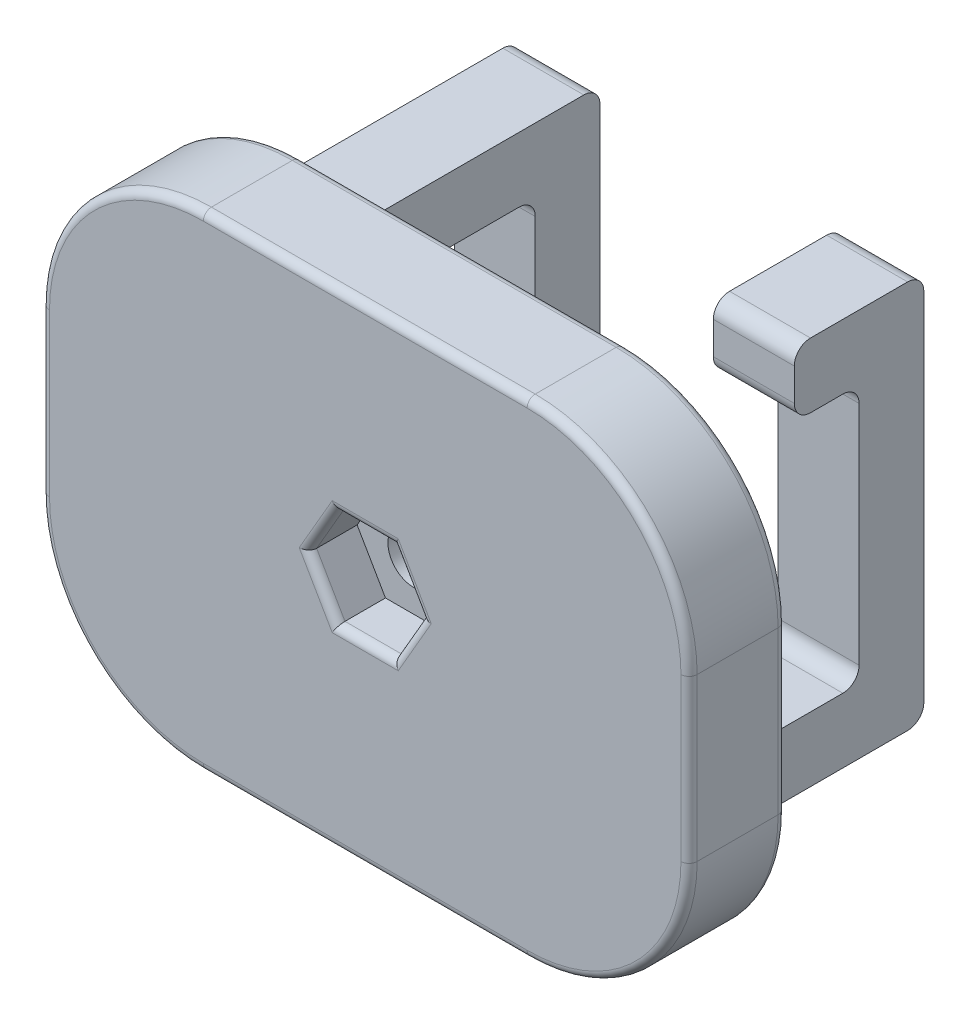
from build123d import *

# Parameters (mm, degrees)
BOSS_EXTRUDE1_DEPTH = 6
SKETCH2_W           = 7.6
SKETCH2_H           = 8.4
BOSS_EXTRUDE2_DEPTH = 4
SKETCH3_W           = 40
SKETCH3_H           = 30
BOSS_EXTRUDE3_DEPTH = 6
BOSS_EXTRUDE4_DEPTH = 2.5
BOSS_EXTRUDE5_DEPTH = 2.5
FILLET1_R           = 10
SKETCH8_R           = 1.6
CUT_EXTRUDE1_DEPTH  = 34.2
FILLET3_R           = 0.5
FILLET4_R           = 0.5
FILLET5_R           = 0.5
SKETCH9_R           = 14.329528823
CUT_EXTRUDE2_DEPTH  = 12.2
CUT_EXTRUDE3_DEPTH  = 3
FILLET6_R           = 0.5
FILLET7_R           = 1
FILLET8_R           = 1.5
FILLET9_R           = 0.3


with BuildPart() as part:
    # Sketch1 → Boss-Extrude1 (new body, symmetric)
    with BuildSketch(Plane(origin=(0, 0, 0), x_dir=(1, 0, 0), z_dir=(0, 1, 0))):
        Polygon((-8, 0), (8, 0), (8, 3.6), (4.3, 7.2), (-4.3, 7.2), (-8, 3.6), align=None)
    extrude(amount=BOSS_EXTRUDE1_DEPTH, both=True)

    # Sketch2 → Boss-Extrude2 (add)
    with BuildSketch(Plane(origin=(0, 0, -7.2), x_dir=(-1, 0, 0), z_dir=(0, 0, -1))):
        Rectangle(SKETCH2_W, SKETCH2_H)
    extrude(amount=BOSS_EXTRUDE2_DEPTH)

    # Sketch3 → Boss-Extrude3 (add)
    with BuildSketch(Plane(origin=(0, 0, -11.2), x_dir=(-1, 0, 0), z_dir=(0, 0, -1))):
        Rectangle(SKETCH3_W, SKETCH3_H)
    extrude(amount=BOSS_EXTRUDE3_DEPTH)

    # Sketch6 → Boss-Extrude4 (add, symmetric)
    with BuildSketch(Plane.ZY.offset(10)):
        Polygon((-29.2, 8), (-17.2, 8), (-17.2, 12), (-33.2, 12), (-33.2, -12), (-25.2, -12), (-25.2, -8), (-29.2, -8), align=None)
    extrude(amount=BOSS_EXTRUDE4_DEPTH, both=True)

    # Sketch7 → Boss-Extrude5 (add, symmetric)
    with BuildSketch(Plane(origin=(10, 0, 0), x_dir=(0, 0, -1), z_dir=(1, 0, 0))):
        Polygon((25.2, 12), (25.2, 8), (29.2, 8), (29.2, -8), (17.2, -8), (17.2, -12), (33.2, -12), (33.2, 12), align=None)
    extrude(amount=BOSS_EXTRUDE5_DEPTH, both=True)

    # Fillet1
    fillet1_edges = [part.edges().sort_by_distance(p)[0] for p in [
        (-20, -15, -14.2),
        (-20, 15, -14.2),
        (20, 15, -14.2),
        (20, -15, -14.2),
    ]]
    fillet(fillet1_edges, radius=FILLET1_R)

    # Sketch8 → Cut-Extrude1 (cut, through all)
    with BuildSketch(Plane.XY):
        Circle(SKETCH8_R)
    extrude(amount=-CUT_EXTRUDE1_DEPTH, mode=Mode.SUBTRACT)

    # Fillet3
    fillet3_edges = [part.edges().sort_by_distance(p)[0] for p in [
        (-6.15, 6, -5.4),
        (-8, 6, -1.8),
        (0, 6, 0),
        (8, 6, -1.8),
        (6.15, 6, -5.4),
        (8, -6, -1.8),
        (0, -6, 0),
        (-8, -6, -1.8),
        (-6.15, -6, -5.4),
        (0, -6, -7.2),
        (6.15, -6, -5.4),
        (0, 6, -7.2),
    ]]
    fillet(fillet3_edges, radius=FILLET3_R)

    # Fillet4
    fillet4_edges = [part.edges().sort_by_distance(p)[0] for p in [
        (-20, 0, -11.2),
        (-20, 0, -17.2),
        (0, -15, -11.2),
        (20, 0, -11.2),
        (0, 15, -11.2),
        (17.071067812, 12.071067812, -11.2),
        (17.071067812, -12.071067812, -11.2),
        (-17.071067812, 12.071067812, -11.2),
        (-17.071067812, -12.071067812, -11.2),
        (0, -15, -17.2),
        (0, 15, -17.2),
        (20, 0, -17.2),
        (17.071067812, 12.071067812, -17.2),
        (17.071067812, -12.071067812, -17.2),
        (-17.071067812, 12.071067812, -17.2),
        (-17.071067812, -12.071067812, -17.2),
    ]]
    fillet(fillet4_edges, radius=FILLET4_R)

    # Fillet5
    fillet5_edges = [part.edges().sort_by_distance(p)[0] for p in [
        (-3.8, 0, -11.2),
        (0, 4.2, -11.2),
        (3.8, 0, -11.2),
        (0, -4.2, -11.2),
    ]]
    fillet(fillet5_edges, radius=FILLET5_R)

    # Sketch9 → Cut-Extrude2 (cut, through all)
    with BuildSketch(Plane.XY.offset(-11.2)):
        Circle(SKETCH9_R)
    extrude(amount=CUT_EXTRUDE2_DEPTH, mode=Mode.SUBTRACT)

    # Sketch10 → Cut-Extrude3 (cut)
    with BuildSketch(Plane.XY.offset(-11.2)):
        Polygon((3.5, 0), (1.75, 3.031088913), (-1.75, 3.031088913), (-3.5, 0), (-1.75, -3.031088913), (1.75, -3.031088913), align=None)
    extrude(amount=-CUT_EXTRUDE3_DEPTH, mode=Mode.SUBTRACT)

    # Fillet6
    fillet6_edges = [part.edges().sort_by_distance(p)[0] for p in [
        (2.625, -1.515544457, -11.2),
        (2.625, 1.515544457, -11.2),
        (0, 3.031088913, -11.2),
        (-2.625, 1.515544457, -11.2),
        (-2.625, -1.515544457, -11.2),
        (0, -3.031088913, -11.2),
    ]]
    fillet(fillet6_edges, radius=FILLET6_R)

    # Fillet7
    fillet7_edges = [part.edges().sort_by_distance(p)[0] for p in [
        (-10, 8, -29.2),
        (-10, 12, -33.2),
        (-10, -12, -33.2),
        (-10, -12, -25.2),
        (-10, -8, -25.2),
        (-10, -8, -29.2),
        (10, -12, -33.2),
        (10, 12, -33.2),
        (10, 12, -25.2),
        (10, 8, -25.2),
        (10, 8, -29.2),
        (10, -8, -29.2),
    ]]
    fillet(fillet7_edges, radius=FILLET7_R)

    # Fillet8
    fillet8_edges = [part.edges().sort_by_distance(p)[0] for p in [
        (-7.5, 10, -17.2),
        (-10, 8, -17.2),
        (-10, 12, -17.2),
        (-12.5, 10, -17.2),
        (10, -12, -17.2),
        (7.5, -10, -17.2),
        (10, -8, -17.2),
        (12.5, -10, -17.2),
    ]]
    fillet(fillet8_edges, radius=FILLET8_R)

    # Fillet9
    fillet9_edges = [part.edges().sort_by_distance(p)[0] for p in [
        (-1.6, 0, -17.2),
    ]]
    fillet(fillet9_edges, radius=FILLET9_R)


solid = part.part
